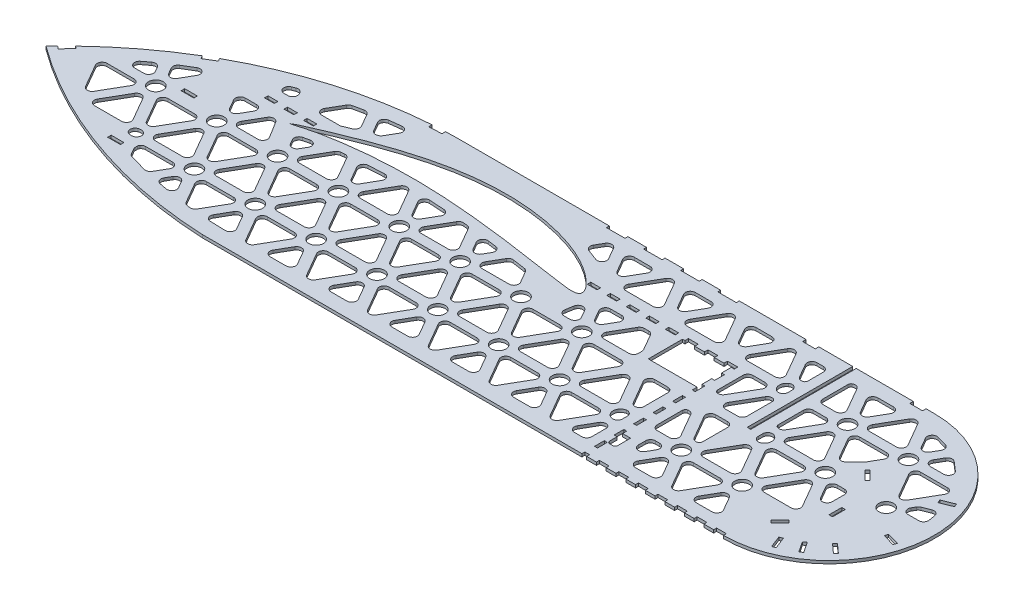
from build123d import *

# Parameters (mm, degrees)
BOSS_EXTRUDE1_DEPTH = 3
SKETCH2_R           = 7.5
SKETCH2_W           = 3.6
SKETCH2_H           = 13
SKETCH2_W_2         = 13
SKETCH2_H_2         = 3.6
SKETCH2_W_3         = 19
SKETCH2_H_3         = 3
SKETCH2_W_4         = 10
SKETCH2_W_5         = 3
SKETCH2_H_4         = 10
SKETCH2_W_6         = 4.93
SKETCH2_H_5         = 108
CUT_EXTRUDE1_DEPTH  = 934.342916617


with BuildPart() as part:
    # Sketch1 → Boss-Extrude1 (new body)
    with BuildSketch(Plane(origin=(0, 0, 0), x_dir=(1, 0, 0), z_dir=(0, 1, 0))):
        with BuildLine():
            Line((266.408252791, 0), (800, 0))
            ThreePointArc((800, 0), (908, 108), (800, 216))
            Line((800, 216), (316.294556964, 216))
            ThreePointArc((316.294556964, 216), (154.432198565, 182.326352039), (19.429068043, 86.893169221))
            ThreePointArc((19.429068043, 86.893169221), (136.475600537, 25.133273094), (266.408252791, 0))
        make_face()
    extrude(amount=BOSS_EXTRUDE1_DEPTH)

    # Sketch2 → Cut-Extrude1 (cut, through all)
    with BuildSketch(Plane.XZ):
        with Locations(Location((173.099021948, -108, 0), (0, 0, 90))):
            Circle(SKETCH2_R)
        with Locations(Location((204.259275985, -54.02885683, 0), (0, 0, 270))):
            Circle(SKETCH2_R)
        with Locations(Location((235.419021948, -108, 0), (0, 0, 90))):
            Circle(SKETCH2_R)
        with Locations(Location((266.579275985, -54.02885683, 0), (0, 0, 270))):
            Circle(SKETCH2_R)
        with Locations(Location((297.739021948, -108, 0), (0, 0, 90))):
            Circle(SKETCH2_R)
        with Locations(Location((328.899275985, -54.02885683, 0), (0, 0, 270))):
            Circle(SKETCH2_R)
        with Locations(Location((360.059021948, -108, 0), (0, 0, 90))):
            Circle(SKETCH2_R)
        with Locations(Location((391.219275985, -54.02885683, 0), (0, 0, 270))):
            Circle(SKETCH2_R)
        with Locations(Location((422.379021948, -108, 0), (0, 0, 90))):
            Circle(SKETCH2_R)
        with Locations(Location((453.539275985, -54.02885683, 0), (0, 0, 270))):
            Circle(SKETCH2_R)
        with Locations(Location((484.699021948, -108, 0), (0, 0, 90))):
            Circle(SKETCH2_R)
        with Locations(Location((515.859275985, -54.02885683, 0), (0, 0, 270))):
            Circle(SKETCH2_R)
        with Locations(Location((547.019021948, -108, 0), (0, 0, 90))):
            Circle(SKETCH2_R)
        with Locations(Location((578.179275985, -54.02885683, 0), (0, 0, 270))):
            Circle(SKETCH2_R)
        with Locations(Location((702.819275985, -54.02885683, 0), (0, 0, 270))):
            Circle(SKETCH2_R)
        with Locations(Location((765.139275985, -54.02885683, 0), (0, 0, 270))):
            Circle(SKETCH2_R)
        with Locations(Location((796.299021948, -108, 0), (0, 0, 90))):
            Circle(SKETCH2_R)
        with Locations(Location((858.619021948, -108, 0), (0, 0, 90))):
            Circle(SKETCH2_R)
        with Locations(Location((765.139275985, -161.96885683, 0), (0, 0, 270))):
            Circle(SKETCH2_R)
        with Locations(Location((827.459275985, -161.96885683, 0), (0, 0, 270))):
            Circle(SKETCH2_R)
        Polygon((647.57, -153), (637.57, -153), (637.57, -156.6), (627.57, -156.6), (627.57, -153), (617.57, -153), (617.57, -156.6), (607.57, -156.6), (607.57, -153), (605.07, -153), (605.07, -118), (655.07, -118), (655.07, -113), (658.07, -113), (658.07, -123), (655.07, -123), (655.07, -133), (658.07, -133), (658.07, -143), (655.07, -143), (655.07, -153), (658.07, -153), (658.07, -156.6), (647.57, -156.6), align=None)
        Polygon((823.689305433, -121.232773417), (814.496917278, -130.425161573), (817.04250169, -132.970745985), (826.234889846, -123.77835783), align=None)
        Polygon((833.216286063, -28.127768374), (837.957262065, -16.0230938), (834.605198337, -14.710208137), (829.864222335, -26.814882712), align=None)
        with Locations((837.65655194, -78.816857664)):
            Rectangle(SKETCH2_W, SKETCH2_H)
        with BuildLine():
            Line((658.07, -25.473381029), (658.07, -33))
            Line((658.07, -33), (655.07, -33))
            Line((655.07, -33), (655.07, -43))
            Line((655.07, -43), (658.07, -43))
            Line((658.07, -43), (658.07, -38.673381029))
            Line((658.07, -38.673381029), (666.27, -38.673381029))
            Line((666.27, -38.673381029), (666.27, -25.473381029))
            ThreePointArc((666.27, -25.473381029), (665.537766953, -23.705614076), (663.77, -22.973381029))
            Line((663.77, -22.973381029), (660.57, -22.973381029))
            ThreePointArc((660.57, -22.973381029), (658.802233047, -23.705614076), (658.07, -25.473381029))
        make_face()
        with BuildLine():
            Line((212.57, -142.861782597), (212.57, -142.894782597))
            add(Edge.make_bspline(
                [(212.57, -142.894782597), (212.815137814, -143.060102486), (213.721483955, -143.671338431), (215.664179604, -144.820627165), (218.723437449, -146.377902142), (222.783765044, -148.180430449), (227.75908382, -150.380753256), (233.673151887, -152.972942719), (243.334631626, -157.073964415), (254.071597155, -161.528560196), (265.811315632, -166.151386352), (275.559769605, -169.792616013), (285.820264156, -173.389650289), (300.213165162, -178.042893994), (315.047470761, -182.21442891), (330.216772764, -185.678244178), (341.716798025, -187.862793988), (353.238408154, -189.570546018), (364.74982071, -190.789827969), (376.222154657, -191.489317525), (387.611451467, -191.686885836), (398.853751386, -191.364655348), (413.421420996, -190.296341642), (427.580802498, -188.300042396), (441.195366572, -185.427458978), (450.821943115, -182.919735681), (459.948918056, -180.069695278), (468.511745548, -176.887644359), (476.453624938, -173.424739179), (483.715148146, -169.728859345), (490.24814377, -165.884833696), (496.019667562, -162.00694583), (500.998027396, -158.185747413), (505.147593549, -154.484087589), (508.447339472, -150.982728864), (510.852240131, -147.780842115), (512.23052565, -145.118995071), (512.672376723, -143.038033672), (512.365957104, -141.293980261), (510.836297954, -139.867947677), (508.300825673, -139.204557497), (504.990749494, -138.996901122), (500.845143819, -139.232879923), (495.886387834, -139.807005807), (490.127383335, -140.633765729), (483.600688534, -141.61415409), (476.345974836, -142.681971784), (468.41886468, -143.870863791), (459.86962452, -145.152957933), (447.40415706, -147.014008038), (434.302787697, -148.89198326), (413.230560269, -151.680307043), (394.916461571, -153.770522792), (372.413070638, -155.785169178), (353.278576878, -157.097400442), (334.10390548, -157.72050793), (318.83753012, -157.719300437), (307.569298967, -157.463067348), (296.54483902, -156.942386113), (285.853643217, -156.19861473), (275.586288909, -155.254588864), (265.829573747, -154.156930461), (256.673464041, -152.912824912), (248.205041684, -151.55854436), (240.510067524, -150.123302558), (233.666056009, -148.664077742), (227.735558734, -147.229571507), (222.771530443, -145.80558608), (218.774640723, -144.512633605), (215.724793866, -143.595242016), (213.753356987, -143.096728121), (212.816237246, -142.910670921), (212.57, -142.861782597)],
                knots=[0, 0, 0, 0, 0.001413477, 0.005226038, 0.010781091, 0.017815608, 0.026460951, 0.036790889, 0.048685593, 0.076639155, 0.092362872, 0.109003461, 0.126386903, 0.144339126, 0.181312719, 0.200023431, 0.218712626, 0.237261299, 0.255692478, 0.274037197, 0.292192583, 0.310132767, 0.327788163, 0.362001934, 0.378421226, 0.394286639, 0.40954344, 0.424114253, 0.43793778, 0.450941833, 0.463044023, 0.474154417, 0.484164575, 0.493023962, 0.500713088, 0.507125739, 0.512129705, 0.514904185, 0.517171427, 0.520261618, 0.5242453, 0.529497961, 0.536092185, 0.54406114, 0.553363127, 0.563904543, 0.575614949, 0.588420092, 0.60222661, 0.616944448, 0.648675826, 0.665501113, 0.718564132, 0.736789145, 0.773513212, 0.810244924, 0.828488569, 0.846493195, 0.864125178, 0.88124851, 0.897725282, 0.913415058, 0.928184346, 0.941897285, 0.954411455, 0.965602702, 0.975349728, 0.983575522, 0.990284579, 0.99543259, 0.998799869, 1, 1, 1, 1], degree=3))
        make_face()
        with Locations((134.542485822, -118.459135811)):
            Rectangle(SKETCH2_W_2, SKETCH2_H_2)
        with Locations((138.193962825, -39.604200299)):
            Rectangle(SKETCH2_W_2, SKETCH2_H_2)
        Polygon((879.46612068, -142.176464253), (891.512779688, -147.062976991), (892.865967831, -143.726979112), (880.819308823, -138.840466374), align=None)
        Polygon((883.56409693, -85.640734603), (896.049682188, -82.019939003), (895.047000329, -78.562392317), (882.561415072, -82.183187916), align=None)
        Polygon((865.40073975, -51.381643569), (875.050147879, -42.670218728), (872.637753308, -39.998074939), (862.988345179, -48.709499779), align=None)
        Polygon((849.114653162, -36.791532178), (856.271451565, -25.938871831), (853.266099469, -23.956989196), (846.109301065, -34.809649543), align=None)
        Polygon((822.408918344, -44.734564455), (813.216530188, -35.542176299), (810.670945776, -38.087760711), (819.863333931, -47.280148867), align=None)
        with Locations((785, -214.2)):
            Rectangle(SKETCH2_W_2, SKETCH2_H_2)
        with Locations((675.107627624, -214.2)):
            Rectangle(SKETCH2_W_2, SKETCH2_H_2)
        with Locations((590.701810534, -214.5)):
            Rectangle(SKETCH2_W_3, SKETCH2_H_3)
        with Locations((552.701810534, -214.5)):
            Rectangle(SKETCH2_W_3, SKETCH2_H_3)
        with Locations((514.701810534, -214.5)):
            Rectangle(SKETCH2_W_3, SKETCH2_H_3)
        with Locations((476.701810534, -214.5)):
            Rectangle(SKETCH2_W_3, SKETCH2_H_3)
        Polygon((286.653605669, -215.067910052), (299.639993398, -215.662665262), (299.804694841, -212.066434814), (286.818307112, -211.471679604), align=None)
        Polygon((107.891846949, -158.40758228), (119.051202256, -165.076074548), (120.897861653, -161.98579154), (109.738506346, -155.317299272), align=None)
        Polygon((25.225136805, -93.110530953), (34.089712558, -102.619437132), (36.722948115, -100.164631538), (27.858372362, -90.65572536), align=None)
        with Locations((532.57, -154.8)):
            Rectangle(SKETCH2_W_4, SKETCH2_H_2)
        with Locations((552.57, -154.8)):
            Rectangle(SKETCH2_W_4, SKETCH2_H_2)
        with Locations((572.57, -154.8)):
            Rectangle(SKETCH2_W_4, SKETCH2_H_2)
        with Locations((592.57, -154.8)):
            Rectangle(SKETCH2_W_4, SKETCH2_H_2)
        with Locations((656.57, -98)):
            Rectangle(SKETCH2_W_5, SKETCH2_H_4)
        with Locations((656.57, -78)):
            Rectangle(SKETCH2_W_5, SKETCH2_H_4)
        with Locations((656.57, -58)):
            Rectangle(SKETCH2_W_5, SKETCH2_H_4)
        with Locations((656.57, -18)):
            Rectangle(SKETCH2_W_5, SKETCH2_H_4)
        with Locations((657.535, -1.5)):
            Rectangle(SKETCH2_W_6, SKETCH2_H_3)
        with Locations((675, -1.5)):
            Rectangle(SKETCH2_W_4, SKETCH2_H_3)
        with Locations((695, -1.5)):
            Rectangle(SKETCH2_W_4, SKETCH2_H_3)
        with Locations((715, -1.5)):
            Rectangle(SKETCH2_W_4, SKETCH2_H_3)
        with Locations((735, -1.5)):
            Rectangle(SKETCH2_W_4, SKETCH2_H_3)
        with Locations((755, -1.5)):
            Rectangle(SKETCH2_W_4, SKETCH2_H_3)
        with Locations((775, -1.5)):
            Rectangle(SKETCH2_W_4, SKETCH2_H_3)
        with Locations((795, -1.5)):
            Rectangle(SKETCH2_W_4, SKETCH2_H_3)
        with Locations((182.07, -154.8)):
            Rectangle(SKETCH2_W_4, SKETCH2_H_2)
        with Locations((202.07, -154.8)):
            Rectangle(SKETCH2_W_4, SKETCH2_H_2)
        with Locations((222.07, -154.8)):
            Rectangle(SKETCH2_W_4, SKETCH2_H_2)
        with Locations((512.57, -154.8)):
            Rectangle(SKETCH2_W_4, SKETCH2_H_2)
        with BuildLine():
            Line((92.609657042, -66.52885683), (106.449403004, -90.5))
            ThreePointArc((106.449403004, -90.5), (110.779530023, -93), (115.109657042, -90.5))
            Line((115.109657042, -90.5), (128.949403004, -66.52885683))
            ThreePointArc((128.949403004, -66.52885683), (128.949403004, -61.52885683), (124.619275985, -59.02885683))
            Line((124.619275985, -59.02885683), (96.939784061, -59.02885683))
            ThreePointArc((96.939784061, -59.02885683), (92.609657042, -61.52885683), (92.609657042, -66.52885683))
        make_face()
        with Locations((718.2, -162)):
            Rectangle(SKETCH2_W, SKETCH2_H_5)
        with BuildLine():
            Line((645.07, -98), (645.07, -72.790783298))
            ThreePointArc((645.07, -72.790783298), (644.904453921, -71.807995952), (644.426086022, -70.933673))
            ThreePointArc((644.426086022, -70.933673), (640.139794282, -69.041796282), (636.169148966, -71.52885683))
            Line((636.169148966, -71.52885683), (622.329403004, -95.5))
            ThreePointArc((622.329403004, -95.5), (622.329403004, -100.5), (626.659530023, -103))
            Line((626.659530023, -103), (640.07, -103))
            ThreePointArc((640.07, -103), (643.605533906, -101.535533906), (645.07, -98))
        make_face()
        with BuildLine():
            Line((706.4, -98), (706.4, -72.115023081))
            ThreePointArc((706.4, -72.115023081), (705.809694801, -70.32802253), (704.271086022, -69.244272457))
            ThreePointArc((704.271086022, -69.244272457), (700.981884192, -69.378696467), (698.489148966, -71.52885683))
            Line((698.489148966, -71.52885683), (684.649403004, -95.5))
            ThreePointArc((684.649403004, -95.5), (684.649403004, -100.5), (688.979530023, -103))
            Line((688.979530023, -103), (701.4, -103))
            ThreePointArc((701.4, -103), (704.935533906, -101.535533906), (706.4, -98))
        make_face()
        with BuildLine():
            Line((552.794352734, -143), (541.244707312, -143))
            ThreePointArc((541.244707312, -143), (536.914580293, -140.5), (536.914580293, -135.5))
            Line((536.914580293, -135.5), (542.689403004, -125.497713659))
            ThreePointArc((542.689403004, -125.497713659), (547.019530023, -122.997713659), (551.349657042, -125.497713659))
            Line((551.349657042, -125.497713659), (557.124479753, -135.5))
            ThreePointArc((557.124479753, -135.5), (557.124479753, -140.5), (552.794352734, -143))
        make_face()
        with BuildLine():
            Line((575.887855426, -143), (580.470696544, -143))
            ThreePointArc((580.470696544, -143), (582.970696544, -142.330127019), (584.800823563, -140.5))
            Line((584.800823563, -140.5), (594.400127019, -123.873518698))
            ThreePointArc((594.400127019, -123.873518698), (594.899629131, -122.667613923), (595.07, -121.373518698))
            Line((595.07, -121.373518698), (595.07, -117.997713659))
            ThreePointArc((595.07, -117.997713659), (593.605533906, -114.462179753), (590.07, -112.997713659))
            Line((590.07, -112.997713659), (564.339530023, -112.997713659))
            ThreePointArc((564.339530023, -112.997713659), (560.009403004, -115.497713659), (560.009403004, -120.497713659))
            Line((560.009403004, -120.497713659), (571.557728407, -140.5))
            ThreePointArc((571.557728407, -140.5), (573.387855426, -142.330127019), (575.887855426, -143))
        make_face()
        with BuildLine():
            Line((520.098230566, -126.918739873), (518.751948683, -118.817465479))
            ThreePointArc((518.751948683, -118.817465479), (519.869968887, -114.765024062), (523.684305814, -112.997799001))
            Line((523.684305814, -112.997799001), (529.698508401, -112.997799001))
            ThreePointArc((529.698508401, -112.997799001), (534.039307761, -115.500026879), (534.030725675, -120.510377144))
            Line((534.030725675, -120.510377144), (529.360714716, -128.599073396))
            ThreePointArc((529.360714716, -128.599073396), (524.138090939, -131.018773543), (520.098230566, -126.918739873))
        make_face()
        with BuildLine():
            Line((645.07, -56.491725508), (645.07, -51.565988151))
            ThreePointArc((645.07, -51.565988151), (643.287704162, -47.738929238), (639.211448029, -46.640250794))
            ThreePointArc((639.211448029, -46.640250794), (632.999275985, -54.02885683), (639.211448029, -61.417462866))
            ThreePointArc((639.211448029, -61.417462866), (643.287704162, -60.318784422), (645.07, -56.491725508))
        make_face()
        with BuildLine():
            Line((632.399711718, -15), (640.07, -15))
            ThreePointArc((640.07, -15), (643.605533906, -16.464466094), (645.07, -20))
            Line((645.07, -20), (645.07, -35.266930361))
            ThreePointArc((645.07, -35.266930361), (644.904453921, -36.249717707), (644.426086022, -37.124040659))
            ThreePointArc((644.426086022, -37.124040659), (640.139794282, -39.015917377), (636.169148966, -36.52885683))
            Line((636.169148966, -36.52885683), (628.069584699, -22.5))
            ThreePointArc((628.069584699, -22.5), (628.069584699, -17.5), (632.399711718, -15))
        make_face()
        with BuildLine():
            Line((586.278840252, -15), (570.079711718, -15))
            ThreePointArc((570.079711718, -15), (565.749584699, -17.5), (565.749584699, -22.5))
            Line((565.749584699, -22.5), (573.849148966, -36.52885683))
            ThreePointArc((573.849148966, -36.52885683), (578.179275985, -39.02885683), (582.509403004, -36.52885683))
            Line((582.509403004, -36.52885683), (590.608967271, -22.5))
            ThreePointArc((590.608967271, -22.5), (590.608967271, -17.5), (586.278840252, -15))
        make_face()
        with BuildLine():
            Line((523.958840252, -15), (507.759711718, -15))
            ThreePointArc((507.759711718, -15), (503.429584699, -17.5), (503.429584699, -22.5))
            Line((503.429584699, -22.5), (511.529148966, -36.52885683))
            ThreePointArc((511.529148966, -36.52885683), (515.859275985, -39.02885683), (520.189403004, -36.52885683))
            Line((520.189403004, -36.52885683), (528.288967271, -22.5))
            ThreePointArc((528.288967271, -22.5), (528.288967271, -17.5), (523.958840252, -15))
        make_face()
        with BuildLine():
            Line((461.638840252, -15), (445.439711718, -15))
            ThreePointArc((445.439711718, -15), (441.109584699, -17.5), (441.109584699, -22.5))
            Line((441.109584699, -22.5), (449.209148966, -36.52885683))
            ThreePointArc((449.209148966, -36.52885683), (453.539275985, -39.02885683), (457.869403004, -36.52885683))
            Line((457.869403004, -36.52885683), (465.968967271, -22.5))
            ThreePointArc((465.968967271, -22.5), (465.968967271, -17.5), (461.638840252, -15))
        make_face()
        with BuildLine():
            Line((399.318840252, -15), (383.119711718, -15))
            ThreePointArc((383.119711718, -15), (378.789584699, -17.5), (378.789584699, -22.5))
            Line((378.789584699, -22.5), (386.889148966, -36.52885683))
            ThreePointArc((386.889148966, -36.52885683), (391.219275985, -39.02885683), (395.549403004, -36.52885683))
            Line((395.549403004, -36.52885683), (403.648967271, -22.5))
            ThreePointArc((403.648967271, -22.5), (403.648967271, -17.5), (399.318840252, -15))
        make_face()
        with BuildLine():
            Line((336.998840252, -15), (320.799711718, -15))
            ThreePointArc((320.799711718, -15), (316.469584699, -17.5), (316.469584699, -22.5))
            Line((316.469584699, -22.5), (324.569148966, -36.52885683))
            ThreePointArc((324.569148966, -36.52885683), (328.899275985, -39.02885683), (333.229403004, -36.52885683))
            Line((333.229403004, -36.52885683), (341.328967271, -22.5))
            ThreePointArc((341.328967271, -22.5), (341.328967271, -17.5), (336.998840252, -15))
        make_face()
        with BuildLine():
            Line((274.360045884, -15.282400069), (258.767288601, -15.772807908))
            ThreePointArc((258.767288601, -15.772807908), (254.555574733, -18.338713906), (254.594338874, -23.270336827))
            Line((254.594338874, -23.270336827), (262.249148966, -36.52885683))
            ThreePointArc((262.249148966, -36.52885683), (266.579275985, -39.02885683), (270.909403004, -36.52885683))
            Line((270.909403004, -36.52885683), (278.847350195, -22.779928988))
            ThreePointArc((278.847350195, -22.779928988), (278.807515978, -17.712169718), (274.360045884, -15.282400069))
        make_face()
        with BuildLine():
            Line((236.201288355, -17.460544209), (233.266650301, -17.806658494))
            ThreePointArc((233.266650301, -17.806658494), (231.102572468, -18.596236849), (229.522169389, -20.272241908))
            Line((229.522169389, -20.272241908), (217.249657042, -41.52885683))
            ThreePointArc((217.249657042, -41.52885683), (217.249657042, -46.52885683), (221.579784061, -49.02885683))
            Line((221.579784061, -49.02885683), (249.259275985, -49.02885683))
            ThreePointArc((249.259275985, -49.02885683), (253.589403004, -46.52885683), (253.589403004, -41.52885683))
            Line((253.589403004, -41.52885683), (241.117061481, -19.926127623))
            ThreePointArc((241.117061481, -19.926127623), (239.028598959, -17.956794307), (236.201288355, -17.460544209))
        make_face()
        with BuildLine():
            Line((207.494633676, -21.910678436), (199.990539022, -23.321819719))
            ThreePointArc((199.990539022, -23.321819719), (196.371136733, -26.148340424), (196.58446304, -30.735690869))
            Line((196.58446304, -30.735690869), (199.929148966, -36.52885683))
            ThreePointArc((199.929148966, -36.52885683), (204.259275985, -39.02885683), (208.589403004, -36.52885683))
            Line((208.589403004, -36.52885683), (212.748811731, -29.324549586))
            ThreePointArc((212.748811731, -29.324549586), (212.498109887, -23.933478808), (207.494633676, -21.910678436))
        make_face()
        with BuildLine():
            Line((179.150055874, -27.997329576), (161.65211917, -32.779123773))
            ThreePointArc((161.65211917, -32.779123773), (159.91653169, -33.643069948), (158.640049569, -35.102268457))
            Line((158.640049569, -35.102268457), (155.095886614, -41.240938766))
            ThreePointArc((155.095886614, -41.240938766), (154.796185346, -41.964481631), (154.693962825, -42.740938766))
            Line((154.693962825, -42.740938766), (154.693962825, -45.273125232))
            ThreePointArc((154.693962825, -45.273125232), (154.861455494, -46.261508871), (155.345230971, -47.139527835))
            ThreePointArc((155.345230971, -47.139527835), (157.086463448, -48.531820022), (159.259784061, -49.02885683))
            Line((159.259784061, -49.02885683), (186.939275985, -49.02885683))
            ThreePointArc((186.939275985, -49.02885683), (191.269403004, -46.52885683), (191.269403004, -41.52885683))
            Line((191.269403004, -41.52885683), (184.79824031, -30.32047426))
            ThreePointArc((184.79824031, -30.32047426), (182.37005733, -28.19634095), (179.150055874, -27.997329576))
        make_face()
        with BuildLine():
            Line((142.718854976, -51.404200299), (141.159696995, -51.404200299))
            ThreePointArc((141.159696995, -51.404200299), (136.222418661, -55.614717777), (139.600539014, -61.154887238))
            ThreePointArc((139.600539014, -61.154887238), (141.939275985, -61.52885683), (144.278012956, -61.154887238))
            ThreePointArc((144.278012956, -61.154887238), (147.65613331, -55.614717777), (142.718854976, -51.404200299))
        make_face()
        with BuildLine():
            Line((461.250493905, -134.830482432), (448.398783221, -136.738958248))
            ThreePointArc((448.398783221, -136.738958248), (445.490016846, -136.29567329), (443.33421135, -134.293193316))
            Line((443.33421135, -134.293193316), (435.369408259, -120.497749691))
            ThreePointArc((435.369408259, -120.497749691), (435.369408259, -115.497749691), (439.699535278, -112.997749691))
            Line((439.699535278, -112.997749691), (467.379027202, -112.997749691))
            ThreePointArc((467.379027202, -112.997749691), (471.709128657, -115.49776445), (471.709120136, -120.497749691))
            Line((471.709120136, -120.497749691), (464.846176071, -132.3847175))
            ThreePointArc((464.846176071, -132.3847175), (463.328150328, -134.018975162), (461.250493905, -134.830482432))
        make_face()
        with BuildLine():
            Line((426.925845652, -139.720641866), (418.485277787, -140.811782521))
            ThreePointArc((418.485277787, -140.811782521), (413.683650741, -138.626031677), (413.514118066, -133.353045074))
            Line((413.514118066, -133.353045074), (418.049401778, -125.497703258))
            ThreePointArc((418.049401778, -125.497703258), (422.379528796, -122.997728552), (426.709641212, -125.497728552))
            Line((426.709641212, -125.497728552), (430.614939969, -132.261904418))
            ThreePointArc((430.614939969, -132.261904418), (430.766586965, -136.978591513), (426.925845652, -139.720641866))
        make_face()
        with BuildLine():
            Line((390.081136777, -144.101768792), (393.565851943, -143.749730032))
            ThreePointArc((393.565851943, -143.749730032), (395.778015499, -142.9738928), (397.39341855, -141.275050843))
            Line((397.39341855, -141.275050843), (409.389214293, -120.49772314))
            ThreePointArc((409.389214293, -120.49772314), (409.389198193, -115.497695254), (405.059022874, -112.997723141))
            Line((405.059022874, -112.997723141), (377.37953095, -112.997723141))
            ThreePointArc((377.37953095, -112.997723141), (373.049403931, -115.497723141), (373.049403931, -120.497723141))
            Line((373.049403931, -120.497723141), (385.248449346, -141.627089603))
            ThreePointArc((385.248449346, -141.627089603), (387.299634548, -143.577530502), (390.081136777, -144.101768792))
        make_face()
        with BuildLine():
            Line((367.81241942, -145.896789835), (352.370989088, -146.825868409))
            ThreePointArc((352.370989088, -146.825868409), (347.817628234, -144.463856765), (347.740565597, -139.334894353))
            Line((347.740565597, -139.334894353), (355.729482648, -125.497684124))
            ThreePointArc((355.729482648, -125.497684124), (360.059513786, -122.997684126), (364.389640802, -125.497518057))
            Line((364.389640802, -125.497518057), (371.842249966, -138.405815779))
            ThreePointArc((371.842249966, -138.405815779), (371.915403372, -143.274596371), (367.81241942, -145.896789835))
        make_face()
        with BuildLine():
            Line((305.606957716, -147.098174328), (289.823230268, -146.21830924))
            ThreePointArc((289.823230268, -146.21830924), (285.703474664, -143.604539669), (285.771396564, -138.726059965))
            Line((285.771396564, -138.726059965), (293.409519005, -125.496443823))
            ThreePointArc((293.409519005, -125.496443823), (297.739795297, -122.996883553), (302.069668432, -125.497142128))
            Line((302.069668432, -125.497142128), (310.215378051, -139.605925052))
            ThreePointArc((310.215378051, -139.605925052), (310.144099338, -144.725507291), (305.606957716, -147.098174328))
        make_face()
        with BuildLine():
            Line((267.512893821, -144.227720176), (264.147831755, -143.802865237))
            ThreePointArc((264.147831755, -143.802865237), (262.007328638, -143.006953567), (260.444006324, -141.342245687))
            Line((260.444006324, -141.342245687), (248.409404394, -120.497703695))
            ThreePointArc((248.409404394, -120.497703695), (248.409404394, -115.497703695), (252.739531412, -112.997703695))
            Line((252.739531412, -112.997703695), (280.419023337, -112.997703695))
            ThreePointArc((280.419023337, -112.997703695), (284.749214472, -115.497703695), (284.749182413, -120.497759221))
            Line((284.749182413, -120.497759221), (272.469322428, -141.767100626))
            ThreePointArc((272.469322428, -141.767100626), (270.36253588, -143.745577727), (267.512893821, -144.227720176))
        make_face()
        with BuildLine():
            Line((237.806112566, -138.941760555), (231.616362159, -137.521362349))
            ThreePointArc((231.616362159, -137.521362349), (228.150693228, -134.644805491), (228.404547422, -130.14802903))
            Line((228.404547422, -130.14802903), (231.08939692, -125.497733288))
            ThreePointArc((231.08939692, -125.497733288), (235.419530179, -122.997747037), (239.74964926, -125.497757845))
            Line((239.74964926, -125.497757845), (243.254551867, -131.568427236))
            ThreePointArc((243.254551867, -131.568427236), (242.945674596, -137.039883186), (237.806112566, -138.941760555))
        make_face()
        with BuildLine():
            Line((204.249137645, -137.30425651), (214.592258392, -120.578024173))
            ThreePointArc((214.592258392, -120.578024173), (214.707068234, -115.514032178), (210.33965721, -112.948312555))
            Line((210.33965721, -112.948312555), (190.339641721, -112.948312555))
            ThreePointArc((190.339641721, -112.948312555), (186.009514703, -115.448312555), (186.009514703, -120.448312555))
            Line((186.009514703, -120.448312555), (195.666409445, -137.174544892))
            ThreePointArc((195.666409445, -137.174544892), (199.920979599, -139.673973975), (204.249137645, -137.30425651))
        make_face()
        with BuildLine():
            Line((238.789055642, -193.178883666), (228.708647314, -191.019501181))
            ThreePointArc((228.708647314, -191.019501181), (226.813830813, -190.173170795), (225.425838811, -188.630419066))
            Line((225.425838811, -188.630419066), (217.249657042, -174.46885683))
            ThreePointArc((217.249657042, -174.46885683), (217.249657042, -169.46885683), (221.579784061, -166.96885683))
            Line((221.579784061, -166.96885683), (239.84086708, -166.96885683))
            ThreePointArc((239.84086708, -166.96885683), (240.783887599, -167.058590818), (241.693059721, -167.324571909))
            Line((241.693059721, -167.324571909), (249.348723497, -170.377736034))
            ThreePointArc((249.348723497, -170.377736034), (252.220456221, -173.383567674), (251.826657875, -177.522020954))
            Line((251.826657875, -177.522020954), (244.166501176, -190.789801551))
            ThreePointArc((244.166501176, -190.789801551), (241.866432347, -192.859141081), (238.789055642, -193.178883666))
        make_face()
        with BuildLine():
            Line((269.328402826, -178.125373168), (268.074244735, -177.665632673))
            ThreePointArc((268.074244735, -177.665632673), (264.648654227, -177.659732833), (262.023232079, -179.860156357))
            Line((262.023232079, -179.860156357), (256.580365767, -189.287477348))
            ThreePointArc((256.580365767, -189.287477348), (256.43282805, -194.012453418), (260.287815062, -196.748553083))
            Line((260.287815062, -196.748553083), (272.511141878, -198.28273513))
            ThreePointArc((272.511141878, -198.28273513), (277.29953777, -196.086942771), (277.463946621, -190.821659395))
            Line((277.463946621, -190.821659395), (270.893947655, -179.442087379))
            ThreePointArc((270.893947655, -179.442087379), (270.22687169, -178.646169687), (269.328402826, -178.125373168))
        make_face()
        with BuildLine():
            Line((184.368562123, -177.893150023), (181.14199607, -176.619756451))
            ThreePointArc((181.14199607, -176.619756451), (178.065566192, -171.034645425), (182.97751581, -166.96885683))
            Line((182.97751581, -166.96885683), (186.939275985, -166.96885683))
            ThreePointArc((186.939275985, -166.96885683), (191.269403004, -169.46885683), (191.269403004, -174.46885683))
            Line((191.269403004, -174.46885683), (190.534208882, -175.742250402))
            ThreePointArc((190.534208882, -175.742250402), (187.851005864, -177.963229256), (184.368562123, -177.893150023))
        make_face()
        with BuildLine():
            Line((118.042485822, -109.061475996), (118.042485822, -106.938524004))
            ThreePointArc((118.042485822, -106.938524004), (117.922784929, -105.851012796), (117.56941357, -104.815572013))
            ThreePointArc((117.56941357, -104.815572013), (103.279021948, -108), (117.56941357, -111.184427987))
            ThreePointArc((117.56941357, -111.184427987), (117.922784929, -110.148987204), (118.042485822, -109.061475996))
        make_face()
        with BuildLine():
            Line((115.614267358, -145.121874875), (104.611437032, -138.498480715))
            ThreePointArc((104.611437032, -138.498480715), (102.348875447, -135.464671899), (102.859997042, -131.714747156))
            Line((102.859997042, -131.714747156), (106.449403004, -125.497713659))
            ThreePointArc((106.449403004, -125.497713659), (110.779530023, -122.997713659), (115.109657042, -125.497713659))
            Line((115.109657042, -125.497713659), (122.523081406, -138.338141315))
            ThreePointArc((122.523081406, -138.338141315), (121.696045274, -144.405823229), (115.614267358, -145.121874875))
        make_face()
        with BuildLine():
            Line((87.602210949, -126.905375895), (81.09773809, -121.985445702))
            ThreePointArc((81.09773809, -121.985445702), (79.37384357, -116.406905722), (84.114026067, -112.997713659))
            Line((84.114026067, -112.997713659), (93.459021948, -112.997713659))
            ThreePointArc((93.459021948, -112.997713659), (97.789148966, -115.497713659), (97.789148966, -120.497713659))
            Line((97.789148966, -120.497713659), (94.948625945, -125.417643853))
            ThreePointArc((94.948625945, -125.417643853), (91.610910088, -127.818166283), (87.602210949, -126.905375895))
        make_face()
        with BuildLine():
            Line((178.874352734, -143), (167.324707312, -143))
            ThreePointArc((167.324707312, -143), (162.994580293, -140.5), (162.994580293, -135.5))
            Line((162.994580293, -135.5), (168.769403004, -125.497713659))
            ThreePointArc((168.769403004, -125.497713659), (173.099530023, -122.997713659), (177.429657042, -125.497713659))
            Line((177.429657042, -125.497713659), (183.204479753, -135.5))
            ThreePointArc((183.204479753, -135.5), (183.204479753, -140.5), (178.874352734, -143))
        make_face()
        with BuildLine():
            Line((61.449403004, -95.5), (75.289148966, -71.52885683))
            ThreePointArc((75.289148966, -71.52885683), (79.619275985, -69.02885683), (83.949403004, -71.52885683))
            Line((83.949403004, -71.52885683), (97.789148966, -95.5))
            ThreePointArc((97.789148966, -95.5), (97.789148966, -100.5), (93.459021948, -103))
            Line((93.459021948, -103), (65.779530023, -103))
            ThreePointArc((65.779530023, -103), (61.449403004, -100.5), (61.449403004, -95.5))
        make_face()
        with BuildLine():
            Line((123.769403004, -95.5), (137.609148966, -71.52885683))
            ThreePointArc((137.609148966, -71.52885683), (141.939275985, -69.02885683), (146.269403004, -71.52885683))
            Line((146.269403004, -71.52885683), (160.109148966, -95.5))
            ThreePointArc((160.109148966, -95.5), (160.109148966, -100.5), (155.779021948, -103))
            Line((155.779021948, -103), (128.099530023, -103))
            ThreePointArc((128.099530023, -103), (123.769403004, -100.5), (123.769403004, -95.5))
        make_face()
        with BuildLine():
            Line((154.929657042, -66.52885683), (168.769403004, -90.5))
            ThreePointArc((168.769403004, -90.5), (173.099530023, -93), (177.429657042, -90.5))
            Line((177.429657042, -90.5), (191.269403004, -66.52885683))
            ThreePointArc((191.269403004, -66.52885683), (191.269403004, -61.52885683), (186.939275985, -59.02885683))
            Line((186.939275985, -59.02885683), (159.259784061, -59.02885683))
            ThreePointArc((159.259784061, -59.02885683), (154.929657042, -61.52885683), (154.929657042, -66.52885683))
        make_face()
        with BuildLine():
            Line((186.089403004, -95.5), (199.929148966, -71.52885683))
            ThreePointArc((199.929148966, -71.52885683), (204.259275985, -69.02885683), (208.589403004, -71.52885683))
            Line((208.589403004, -71.52885683), (222.429148966, -95.5))
            ThreePointArc((222.429148966, -95.5), (222.429148966, -100.5), (218.099021948, -103))
            Line((218.099021948, -103), (190.419530023, -103))
            ThreePointArc((190.419530023, -103), (186.089403004, -100.5), (186.089403004, -95.5))
        make_face()
        with BuildLine():
            Line((217.249657042, -66.52885683), (231.089403004, -90.5))
            ThreePointArc((231.089403004, -90.5), (235.419530023, -93), (239.749657042, -90.5))
            Line((239.749657042, -90.5), (253.589403004, -66.52885683))
            ThreePointArc((253.589403004, -66.52885683), (253.589403004, -61.52885683), (249.259275985, -59.02885683))
            Line((249.259275985, -59.02885683), (221.579784061, -59.02885683))
            ThreePointArc((221.579784061, -59.02885683), (217.249657042, -61.52885683), (217.249657042, -66.52885683))
        make_face()
        with BuildLine():
            Line((248.409403004, -95.5), (262.249148966, -71.52885683))
            ThreePointArc((262.249148966, -71.52885683), (266.579275985, -69.02885683), (270.909403004, -71.52885683))
            Line((270.909403004, -71.52885683), (284.749148966, -95.5))
            ThreePointArc((284.749148966, -95.5), (284.749148966, -100.5), (280.419021948, -103))
            Line((280.419021948, -103), (252.739530023, -103))
            ThreePointArc((252.739530023, -103), (248.409403004, -100.5), (248.409403004, -95.5))
        make_face()
        with BuildLine():
            Line((279.569657042, -66.52885683), (293.409403004, -90.5))
            ThreePointArc((293.409403004, -90.5), (297.739530023, -93), (302.069657042, -90.5))
            Line((302.069657042, -90.5), (315.909403004, -66.52885683))
            ThreePointArc((315.909403004, -66.52885683), (315.909403004, -61.52885683), (311.579275985, -59.02885683))
            Line((311.579275985, -59.02885683), (283.899784061, -59.02885683))
            ThreePointArc((283.899784061, -59.02885683), (279.569657042, -61.52885683), (279.569657042, -66.52885683))
        make_face()
        with BuildLine():
            Line((311.579275985, -49.02885683), (283.899784061, -49.02885683))
            ThreePointArc((283.899784061, -49.02885683), (279.569657042, -46.52885683), (279.569657042, -41.52885683))
            Line((279.569657042, -41.52885683), (293.409403004, -17.557713659))
            ThreePointArc((293.409403004, -17.557713659), (297.739530023, -15.057713659), (302.069657042, -17.557713659))
            Line((302.069657042, -17.557713659), (315.909403004, -41.52885683))
            ThreePointArc((315.909403004, -41.52885683), (315.909403004, -46.52885683), (311.579275985, -49.02885683))
        make_face()
        with BuildLine():
            Line((310.729403004, -95.5), (324.569148966, -71.52885683))
            ThreePointArc((324.569148966, -71.52885683), (328.899275985, -69.02885683), (333.229403004, -71.52885683))
            Line((333.229403004, -71.52885683), (347.069148966, -95.5))
            ThreePointArc((347.069148966, -95.5), (347.069148966, -100.5), (342.739021948, -103))
            Line((342.739021948, -103), (315.059530023, -103))
            ThreePointArc((315.059530023, -103), (310.729403004, -100.5), (310.729403004, -95.5))
        make_face()
        with BuildLine():
            Line((341.889657042, -66.52885683), (355.729403004, -90.5))
            ThreePointArc((355.729403004, -90.5), (360.059530023, -93), (364.389657042, -90.5))
            Line((364.389657042, -90.5), (378.229403004, -66.52885683))
            ThreePointArc((378.229403004, -66.52885683), (378.229403004, -61.52885683), (373.899275985, -59.02885683))
            Line((373.899275985, -59.02885683), (346.219784061, -59.02885683))
            ThreePointArc((346.219784061, -59.02885683), (341.889657042, -61.52885683), (341.889657042, -66.52885683))
        make_face()
        with BuildLine():
            Line((373.899275985, -49.02885683), (346.219784061, -49.02885683))
            ThreePointArc((346.219784061, -49.02885683), (341.889657042, -46.52885683), (341.889657042, -41.52885683))
            Line((341.889657042, -41.52885683), (355.729403004, -17.557713659))
            ThreePointArc((355.729403004, -17.557713659), (360.059530023, -15.057713659), (364.389657042, -17.557713659))
            Line((364.389657042, -17.557713659), (378.229403004, -41.52885683))
            ThreePointArc((378.229403004, -41.52885683), (378.229403004, -46.52885683), (373.899275985, -49.02885683))
        make_face()
        with BuildLine():
            Line((373.049403004, -95.5), (386.889148966, -71.52885683))
            ThreePointArc((386.889148966, -71.52885683), (391.219275985, -69.02885683), (395.549403004, -71.52885683))
            Line((395.549403004, -71.52885683), (409.389148966, -95.5))
            ThreePointArc((409.389148966, -95.5), (409.389148966, -100.5), (405.059021948, -103))
            Line((405.059021948, -103), (377.379530023, -103))
            ThreePointArc((377.379530023, -103), (373.049403004, -100.5), (373.049403004, -95.5))
        make_face()
        with BuildLine():
            Line((404.209657042, -66.52885683), (418.049403004, -90.5))
            ThreePointArc((418.049403004, -90.5), (422.379530023, -93), (426.709657042, -90.5))
            Line((426.709657042, -90.5), (440.549403004, -66.52885683))
            ThreePointArc((440.549403004, -66.52885683), (440.549403004, -61.52885683), (436.219275985, -59.02885683))
            Line((436.219275985, -59.02885683), (408.539784061, -59.02885683))
            ThreePointArc((408.539784061, -59.02885683), (404.209657042, -61.52885683), (404.209657042, -66.52885683))
        make_face()
        with BuildLine():
            Line((436.219275985, -49.02885683), (408.539784061, -49.02885683))
            ThreePointArc((408.539784061, -49.02885683), (404.209657042, -46.52885683), (404.209657042, -41.52885683))
            Line((404.209657042, -41.52885683), (418.049403004, -17.557713659))
            ThreePointArc((418.049403004, -17.557713659), (422.379530023, -15.057713659), (426.709657042, -17.557713659))
            Line((426.709657042, -17.557713659), (440.549403004, -41.52885683))
            ThreePointArc((440.549403004, -41.52885683), (440.549403004, -46.52885683), (436.219275985, -49.02885683))
        make_face()
        with BuildLine():
            Line((435.369403004, -95.5), (449.209148966, -71.52885683))
            ThreePointArc((449.209148966, -71.52885683), (453.539275985, -69.02885683), (457.869403004, -71.52885683))
            Line((457.869403004, -71.52885683), (471.709148966, -95.5))
            ThreePointArc((471.709148966, -95.5), (471.709148966, -100.5), (467.379021948, -103))
            Line((467.379021948, -103), (439.699530023, -103))
            ThreePointArc((439.699530023, -103), (435.369403004, -100.5), (435.369403004, -95.5))
        make_face()
        with BuildLine():
            Line((466.529657042, -66.52885683), (480.369403004, -90.5))
            ThreePointArc((480.369403004, -90.5), (484.699530023, -93), (489.029657042, -90.5))
            Line((489.029657042, -90.5), (502.869403004, -66.52885683))
            ThreePointArc((502.869403004, -66.52885683), (502.869403004, -61.52885683), (498.539275985, -59.02885683))
            Line((498.539275985, -59.02885683), (470.859784061, -59.02885683))
            ThreePointArc((470.859784061, -59.02885683), (466.529657042, -61.52885683), (466.529657042, -66.52885683))
        make_face()
        with BuildLine():
            Line((498.539275985, -49.02885683), (470.859784061, -49.02885683))
            ThreePointArc((470.859784061, -49.02885683), (466.529657042, -46.52885683), (466.529657042, -41.52885683))
            Line((466.529657042, -41.52885683), (480.369403004, -17.557713659))
            ThreePointArc((480.369403004, -17.557713659), (484.699530023, -15.057713659), (489.029657042, -17.557713659))
            Line((489.029657042, -17.557713659), (502.869403004, -41.52885683))
            ThreePointArc((502.869403004, -41.52885683), (502.869403004, -46.52885683), (498.539275985, -49.02885683))
        make_face()
        with BuildLine():
            Line((497.689403004, -95.5), (511.529148966, -71.52885683))
            ThreePointArc((511.529148966, -71.52885683), (515.859275985, -69.02885683), (520.189403004, -71.52885683))
            Line((520.189403004, -71.52885683), (534.029148966, -95.5))
            ThreePointArc((534.029148966, -95.5), (534.029148966, -100.5), (529.699021948, -103))
            Line((529.699021948, -103), (502.019530023, -103))
            ThreePointArc((502.019530023, -103), (497.689403004, -100.5), (497.689403004, -95.5))
        make_face()
        with BuildLine():
            Line((528.849657042, -66.52885683), (542.689403004, -90.5))
            ThreePointArc((542.689403004, -90.5), (547.019530023, -93), (551.349657042, -90.5))
            Line((551.349657042, -90.5), (565.189403004, -66.52885683))
            ThreePointArc((565.189403004, -66.52885683), (565.189403004, -61.52885683), (560.859275985, -59.02885683))
            Line((560.859275985, -59.02885683), (533.179784061, -59.02885683))
            ThreePointArc((533.179784061, -59.02885683), (528.849657042, -61.52885683), (528.849657042, -66.52885683))
        make_face()
        with BuildLine():
            Line((560.859275985, -49.02885683), (533.179784061, -49.02885683))
            ThreePointArc((533.179784061, -49.02885683), (528.849657042, -46.52885683), (528.849657042, -41.52885683))
            Line((528.849657042, -41.52885683), (542.689403004, -17.557713659))
            ThreePointArc((542.689403004, -17.557713659), (547.019530023, -15.057713659), (551.349657042, -17.557713659))
            Line((551.349657042, -17.557713659), (565.189403004, -41.52885683))
            ThreePointArc((565.189403004, -41.52885683), (565.189403004, -46.52885683), (560.859275985, -49.02885683))
        make_face()
        with BuildLine():
            Line((560.009403004, -95.5), (573.849148966, -71.52885683))
            ThreePointArc((573.849148966, -71.52885683), (578.179275985, -69.02885683), (582.509403004, -71.52885683))
            Line((582.509403004, -71.52885683), (596.349148966, -95.5))
            ThreePointArc((596.349148966, -95.5), (596.349148966, -100.5), (592.019021948, -103))
            Line((592.019021948, -103), (564.339530023, -103))
            ThreePointArc((564.339530023, -103), (560.009403004, -100.5), (560.009403004, -95.5))
        make_face()
        with BuildLine():
            Line((591.169657042, -66.52885683), (605.009403004, -90.5))
            ThreePointArc((605.009403004, -90.5), (609.339530023, -93), (613.669657042, -90.5))
            Line((613.669657042, -90.5), (627.509403004, -66.52885683))
            ThreePointArc((627.509403004, -66.52885683), (627.509403004, -61.52885683), (623.179275985, -59.02885683))
            Line((623.179275985, -59.02885683), (595.499784061, -59.02885683))
            ThreePointArc((595.499784061, -59.02885683), (591.169657042, -61.52885683), (591.169657042, -66.52885683))
        make_face()
        with BuildLine():
            Line((623.179275985, -49.02885683), (595.499784061, -49.02885683))
            ThreePointArc((595.499784061, -49.02885683), (591.169657042, -46.52885683), (591.169657042, -41.52885683))
            Line((591.169657042, -41.52885683), (605.009403004, -17.557713659))
            ThreePointArc((605.009403004, -17.557713659), (609.339530023, -15.057713659), (613.669657042, -17.557713659))
            Line((613.669657042, -17.557713659), (627.509403004, -41.52885683))
            ThreePointArc((627.509403004, -41.52885683), (627.509403004, -46.52885683), (623.179275985, -49.02885683))
        make_face()
        with BuildLine():
            Line((675.989657042, -90.5), (689.829403004, -66.52885683))
            ThreePointArc((689.829403004, -66.52885683), (689.829403004, -61.52885683), (685.499275985, -59.02885683))
            Line((685.499275985, -59.02885683), (673.07, -59.02885683))
            ThreePointArc((673.07, -59.02885683), (669.534466094, -60.493322924), (668.07, -64.02885683))
            Line((668.07, -64.02885683), (668.07, -89.911139543))
            ThreePointArc((668.07, -89.911139543), (668.656197491, -91.692587675), (670.185704965, -92.777848857))
            ThreePointArc((670.185704965, -92.777848857), (673.486211188, -92.654378146), (675.989657042, -90.5))
        make_face()
        with BuildLine():
            Line((685.499275985, -49.02885683), (681.27, -49.02885683))
            ThreePointArc((681.27, -49.02885683), (677.734466094, -47.564390736), (676.27, -44.02885683))
            Line((676.27, -44.02885683), (676.27, -36.703535944))
            ThreePointArc((676.27, -36.703535944), (679.975904774, -31.873906812), (685.600127019, -34.203535944))
            Line((685.600127019, -34.203535944), (689.829403004, -41.52885683))
            ThreePointArc((689.829403004, -41.52885683), (689.829403004, -46.52885683), (685.499275985, -49.02885683))
        make_face()
        with BuildLine():
            Line((715.809657042, -66.52885683), (729.649403004, -90.5))
            ThreePointArc((729.649403004, -90.5), (733.979530023, -93), (738.309657042, -90.5))
            Line((738.309657042, -90.5), (752.149403004, -66.52885683))
            ThreePointArc((752.149403004, -66.52885683), (752.149403004, -61.52885683), (747.819275985, -59.02885683))
            Line((747.819275985, -59.02885683), (720.139784061, -59.02885683))
            ThreePointArc((720.139784061, -59.02885683), (715.809657042, -61.52885683), (715.809657042, -66.52885683))
        make_face()
        with BuildLine():
            Line((747.819275985, -49.02885683), (720.139784061, -49.02885683))
            ThreePointArc((720.139784061, -49.02885683), (715.809657042, -46.52885683), (715.809657042, -41.52885683))
            Line((715.809657042, -41.52885683), (729.649403004, -17.557713659))
            ThreePointArc((729.649403004, -17.557713659), (733.979530023, -15.057713659), (738.309657042, -17.557713659))
            Line((738.309657042, -17.557713659), (752.149403004, -41.52885683))
            ThreePointArc((752.149403004, -41.52885683), (752.149403004, -46.52885683), (747.819275985, -49.02885683))
        make_face()
        with BuildLine():
            Line((707.149403004, -36.52885683), (715.248967271, -22.5))
            ThreePointArc((715.248967271, -22.5), (715.248967271, -17.5), (710.918840252, -15))
            Line((710.918840252, -15), (694.719711718, -15))
            ThreePointArc((694.719711718, -15), (690.389584699, -17.5), (690.389584699, -22.5))
            Line((690.389584699, -22.5), (698.489148966, -36.52885683))
            ThreePointArc((698.489148966, -36.52885683), (702.819275985, -39.02885683), (707.149403004, -36.52885683))
        make_face()
        with BuildLine():
            Line((746.969403004, -95.5), (760.809148966, -71.52885683))
            ThreePointArc((760.809148966, -71.52885683), (765.139275985, -69.02885683), (769.469403004, -71.52885683))
            Line((769.469403004, -71.52885683), (783.309148966, -95.5))
            ThreePointArc((783.309148966, -95.5), (783.309148966, -100.5), (778.979021948, -103))
            Line((778.979021948, -103), (751.299530023, -103))
            ThreePointArc((751.299530023, -103), (746.969403004, -100.5), (746.969403004, -95.5))
        make_face()
        with BuildLine():
            Line((778.129657042, -66.52885683), (791.969403004, -90.5))
            ThreePointArc((791.969403004, -90.5), (796.299530023, -93), (800.629657042, -90.5))
            Line((800.629657042, -90.5), (814.469403004, -66.52885683))
            ThreePointArc((814.469403004, -66.52885683), (814.469403004, -61.52885683), (810.139275985, -59.02885683))
            Line((810.139275985, -59.02885683), (782.459784061, -59.02885683))
            ThreePointArc((782.459784061, -59.02885683), (778.129657042, -61.52885683), (778.129657042, -66.52885683))
        make_face()
        with BuildLine():
            Line((769.469403004, -36.52885683), (777.568967271, -22.5))
            ThreePointArc((777.568967271, -22.5), (777.568967271, -17.5), (773.238840252, -15))
            Line((773.238840252, -15), (757.039711718, -15))
            ThreePointArc((757.039711718, -15), (752.709584699, -17.5), (752.709584699, -22.5))
            Line((752.709584699, -22.5), (760.809148966, -36.52885683))
            ThreePointArc((760.809148966, -36.52885683), (765.139275985, -39.02885683), (769.469403004, -36.52885683))
        make_face()
        with BuildLine():
            Line((820.85655194, -103), (813.619530023, -103))
            ThreePointArc((813.619530023, -103), (809.289403004, -100.5), (809.289403004, -95.5))
            Line((809.289403004, -95.5), (816.526424921, -82.965110344))
            ThreePointArc((816.526424921, -82.965110344), (822.150647166, -80.635481213), (825.85655194, -85.465110344))
            Line((825.85655194, -85.465110344), (825.85655194, -98))
            ThreePointArc((825.85655194, -98), (824.392085846, -101.535533906), (820.85655194, -103))
        make_face()
        with BuildLine():
            Line((342.739021948, -112.997713659), (315.059530023, -112.997713659))
            ThreePointArc((315.059530023, -112.997713659), (310.729403004, -115.497713659), (310.729403004, -120.497713659))
            Line((310.729403004, -120.497713659), (324.569148966, -144.46885683))
            ThreePointArc((324.569148966, -144.46885683), (328.899275985, -146.96885683), (333.229403004, -144.46885683))
            Line((333.229403004, -144.46885683), (347.069148966, -120.497713659))
            ThreePointArc((347.069148966, -120.497713659), (347.069148966, -115.497713659), (342.739021948, -112.997713659))
        make_face()
        with BuildLine():
            Line((489.029657042, -198.44), (495.863914648, -186.602718594))
            ThreePointArc((495.863914648, -186.602718594), (495.343718282, -180.864751883), (489.764716379, -179.426140047))
            Line((489.764716379, -179.426140047), (478.546320447, -183.669871123))
            ThreePointArc((478.546320447, -183.669871123), (475.606264943, -186.665936295), (475.985264678, -190.84644967))
            Line((475.985264678, -190.84644967), (480.369403004, -198.44))
            ThreePointArc((480.369403004, -198.44), (484.699530023, -200.94), (489.029657042, -198.44))
        make_face()
        with BuildLine():
            Line((503.42826468, -193.5), (511.529148966, -179.46885683))
            ThreePointArc((511.529148966, -179.46885683), (515.859275985, -176.96885683), (520.189403004, -179.46885683))
            Line((520.189403004, -179.46885683), (528.290287291, -193.5))
            ThreePointArc((528.290287291, -193.5), (528.290287291, -198.5), (523.960160272, -201))
            Line((523.960160272, -201), (507.758391699, -201))
            ThreePointArc((507.758391699, -201), (503.42826468, -198.5), (503.42826468, -193.5))
        make_face()
        with BuildLine():
            Line((528.849657042, -174.46885683), (542.689403004, -198.44))
            ThreePointArc((542.689403004, -198.44), (547.019530023, -200.94), (551.349657042, -198.44))
            Line((551.349657042, -198.44), (565.189403004, -174.46885683))
            ThreePointArc((565.189403004, -174.46885683), (565.189403004, -169.46885683), (560.859275985, -166.96885683))
            Line((560.859275985, -166.96885683), (533.179784061, -166.96885683))
            ThreePointArc((533.179784061, -166.96885683), (528.849657042, -169.46885683), (528.849657042, -174.46885683))
        make_face()
        with BuildLine():
            Line((565.74826468, -193.5), (573.849148966, -179.46885683))
            ThreePointArc((573.849148966, -179.46885683), (578.179275985, -176.96885683), (582.509403004, -179.46885683))
            Line((582.509403004, -179.46885683), (590.610287291, -193.5))
            ThreePointArc((590.610287291, -193.5), (590.610287291, -198.5), (586.280160272, -201))
            Line((586.280160272, -201), (570.078391699, -201))
            ThreePointArc((570.078391699, -201), (565.74826468, -198.5), (565.74826468, -193.5))
        make_face()
        with BuildLine():
            Line((591.169657042, -174.46885683), (605.009403004, -198.44))
            ThreePointArc((605.009403004, -198.44), (609.339530023, -200.94), (613.669657042, -198.44))
            Line((613.669657042, -198.44), (627.509403004, -174.46885683))
            ThreePointArc((627.509403004, -174.46885683), (627.509403004, -169.46885683), (623.179275985, -166.96885683))
            Line((623.179275985, -166.96885683), (595.499784061, -166.96885683))
            ThreePointArc((595.499784061, -166.96885683), (591.169657042, -169.46885683), (591.169657042, -174.46885683))
        make_face()
        with BuildLine():
            Line((628.06826468, -193.5), (636.169148966, -179.46885683))
            ThreePointArc((636.169148966, -179.46885683), (640.499275985, -176.96885683), (644.829403004, -179.46885683))
            Line((644.829403004, -179.46885683), (652.930287291, -193.5))
            ThreePointArc((652.930287291, -193.5), (652.930287291, -198.5), (648.600160272, -201))
            Line((648.600160272, -201), (632.398391699, -201))
            ThreePointArc((632.398391699, -201), (628.06826468, -198.5), (628.06826468, -193.5))
        make_face()
        with BuildLine():
            Line((653.489657042, -174.46885683), (667.329403004, -198.44))
            ThreePointArc((667.329403004, -198.44), (671.659530023, -200.94), (675.989657042, -198.44))
            Line((675.989657042, -198.44), (689.829403004, -174.46885683))
            ThreePointArc((689.829403004, -174.46885683), (689.829403004, -169.46885683), (685.499275985, -166.96885683))
            Line((685.499275985, -166.96885683), (657.819784061, -166.96885683))
            ThreePointArc((657.819784061, -166.96885683), (653.489657042, -169.46885683), (653.489657042, -174.46885683))
        make_face()
        with BuildLine():
            Line((685.499275985, -156.96885683), (673.07, -156.96885683))
            ThreePointArc((673.07, -156.96885683), (669.534466094, -155.504390736), (668.07, -151.96885683))
            Line((668.07, -151.96885683), (668.07, -126.086574117))
            ThreePointArc((668.07, -126.086574117), (668.656197491, -124.305125984), (670.185704965, -123.219864803))
            ThreePointArc((670.185704965, -123.219864803), (673.486211188, -123.343335514), (675.989657042, -125.497713659))
            Line((675.989657042, -125.497713659), (689.829403004, -149.46885683))
            ThreePointArc((689.829403004, -149.46885683), (689.829403004, -154.46885683), (685.499275985, -156.96885683))
        make_face()
        with BuildLine():
            Line((690.38826468, -193.5), (698.489148966, -179.46885683))
            ThreePointArc((698.489148966, -179.46885683), (700.981884192, -177.318696467), (704.271086022, -177.184272457))
            ThreePointArc((704.271086022, -177.184272457), (705.809694801, -178.26802253), (706.4, -180.055023081))
            Line((706.4, -180.055023081), (706.4, -196))
            ThreePointArc((706.4, -196), (704.935533906, -199.535533906), (701.4, -201))
            Line((701.4, -201), (694.718391699, -201))
            ThreePointArc((694.718391699, -201), (690.38826468, -198.5), (690.38826468, -193.5))
        make_face()
        with BuildLine():
            Line((738.309657042, -198.44), (752.149403004, -174.46885683))
            ThreePointArc((752.149403004, -174.46885683), (752.149403004, -169.46885683), (747.819275985, -166.96885683))
            Line((747.819275985, -166.96885683), (735, -166.96885683))
            ThreePointArc((735, -166.96885683), (731.464466094, -168.433322924), (730, -171.96885683))
            Line((730, -171.96885683), (730, -197.683708959))
            ThreePointArc((730, -197.683708959), (730.41080272, -199.198983669), (731.530704965, -200.299272397))
            ThreePointArc((731.530704965, -200.299272397), (735.302045705, -200.761924125), (738.309657042, -198.44))
        make_face()
        with BuildLine():
            Line((747.819275985, -156.96885683), (735, -156.96885683))
            ThreePointArc((735, -156.96885683), (731.464466094, -155.504390736), (730, -151.96885683))
            Line((730, -151.96885683), (730, -126.2540047))
            ThreePointArc((730, -126.2540047), (730.41080272, -124.73872999), (731.530704965, -123.638441262))
            ThreePointArc((731.530704965, -123.638441262), (735.302045705, -123.175789534), (738.309657042, -125.497713659))
            Line((738.309657042, -125.497713659), (752.149403004, -149.46885683))
            ThreePointArc((752.149403004, -149.46885683), (752.149403004, -154.46885683), (747.819275985, -156.96885683))
        make_face()
        with BuildLine():
            Line((684.649403004, -120.497713659), (698.489148966, -144.46885683))
            ThreePointArc((698.489148966, -144.46885683), (700.981884192, -146.619017192), (704.271086022, -146.753441202))
            ThreePointArc((704.271086022, -146.753441202), (705.809694801, -145.669691129), (706.4, -143.882690579))
            Line((706.4, -143.882690579), (706.4, -117.997713659))
            ThreePointArc((706.4, -117.997713659), (704.935533906, -114.462179753), (701.4, -112.997713659))
            Line((701.4, -112.997713659), (688.979530023, -112.997713659))
            ThreePointArc((688.979530023, -112.997713659), (684.649403004, -115.497713659), (684.649403004, -120.497713659))
        make_face()
        with BuildLine():
            Line((752.70826468, -193.5), (760.809148966, -179.46885683))
            ThreePointArc((760.809148966, -179.46885683), (765.139275985, -176.96885683), (769.469403004, -179.46885683))
            Line((769.469403004, -179.46885683), (777.570287291, -193.5))
            ThreePointArc((777.570287291, -193.5), (777.570287291, -198.5), (773.240160272, -201))
            Line((773.240160272, -201), (757.038391699, -201))
            ThreePointArc((757.038391699, -201), (752.70826468, -198.5), (752.70826468, -193.5))
        make_face()
        with BuildLine():
            Line((778.129657042, -174.46885683), (791.969403004, -198.44))
            ThreePointArc((791.969403004, -198.44), (796.299530023, -200.94), (800.629657042, -198.44))
            Line((800.629657042, -198.44), (814.469403004, -174.46885683))
            ThreePointArc((814.469403004, -174.46885683), (814.469403004, -169.46885683), (810.139275985, -166.96885683))
            Line((810.139275985, -166.96885683), (782.459784061, -166.96885683))
            ThreePointArc((782.459784061, -166.96885683), (778.129657042, -169.46885683), (778.129657042, -174.46885683))
        make_face()
        with BuildLine():
            Line((810.139275985, -156.96885683), (782.459784061, -156.96885683))
            ThreePointArc((782.459784061, -156.96885683), (778.129657042, -154.46885683), (778.129657042, -149.46885683))
            Line((778.129657042, -149.46885683), (789.977030066, -128.948604816))
            ThreePointArc((789.977030066, -128.948604816), (793.654526124, -126.491380509), (797.842690991, -127.91307091))
            Line((797.842690991, -127.91307091), (807.270700961, -137.34108088))
            ThreePointArc((807.270700961, -137.34108088), (807.701933757, -137.832807641), (808.065294074, -138.376614786))
            Line((808.065294074, -138.376614786), (814.469403004, -149.46885683))
            ThreePointArc((814.469403004, -149.46885683), (814.469403004, -154.46885683), (810.139275985, -156.96885683))
        make_face()
        with BuildLine():
            Line((778.979021948, -112.997713659), (751.299530023, -112.997713659))
            ThreePointArc((751.299530023, -112.997713659), (746.969403004, -115.497713659), (746.969403004, -120.497713659))
            Line((746.969403004, -120.497713659), (760.809148966, -144.46885683))
            ThreePointArc((760.809148966, -144.46885683), (765.139275985, -146.96885683), (769.469403004, -144.46885683))
            Line((769.469403004, -144.46885683), (783.309148966, -120.497713659))
            ThreePointArc((783.309148966, -120.497713659), (783.309148966, -115.497713659), (778.979021948, -112.997713659))
        make_face()
        with BuildLine():
            Line((872.459275985, -156.96885683), (844.779784061, -156.96885683))
            ThreePointArc((844.779784061, -156.96885683), (840.449657042, -154.46885683), (840.449657042, -149.46885683))
            Line((840.449657042, -149.46885683), (854.289403004, -125.497713659))
            ThreePointArc((854.289403004, -125.497713659), (858.619530023, -122.997713659), (862.949657042, -125.497713659))
            Line((862.949657042, -125.497713659), (876.789403004, -149.46885683))
            ThreePointArc((876.789403004, -149.46885683), (876.789403004, -154.46885683), (872.459275985, -156.96885683))
        make_face()
        with BuildLine():
            Line((890.797358727, -125.519701262), (891.905184041, -118.812524657))
            ThreePointArc((891.905184041, -118.812524657), (890.784767876, -114.763061823), (886.972022475, -112.997713659))
            Line((886.972022475, -112.997713659), (875.939530023, -112.997713659))
            ThreePointArc((875.939530023, -112.997713659), (871.609403004, -115.497713659), (871.609403004, -120.497713659))
            Line((871.609403004, -120.497713659), (873.636203924, -124.008235829))
            ThreePointArc((873.636203924, -124.008235829), (874.684863708, -125.280764528), (876.090418051, -126.142990496))
            Line((876.090418051, -126.142990496), (883.988284269, -129.339644931))
            ThreePointArc((883.988284269, -129.339644931), (888.310558699, -129.065545631), (890.797358727, -125.519701262))
        make_face()
        with BuildLine():
            Line((852.622914213, -183.666438218), (861.769807386, -175.749402673))
            ThreePointArc((861.769807386, -175.749402673), (863.182808179, -170.22282264), (858.497579838, -166.96885683))
            Line((858.497579838, -166.96885683), (844.779784061, -166.96885683))
            ThreePointArc((844.779784061, -166.96885683), (840.449657042, -169.46885683), (840.449657042, -174.46885683))
            Line((840.449657042, -174.46885683), (845.020559645, -182.385892375))
            ThreePointArc((845.020559645, -182.385892375), (848.520182458, -184.816436236), (852.622914213, -183.666438218))
        make_face()
        with BuildLine():
            Line((833.04661912, -194.084099959), (822.950581554, -196.958309115))
            ThreePointArc((822.950581554, -196.958309115), (817.638563232, -195.223943105), (817.251417468, -189.649386418))
            Line((817.251417468, -189.649386418), (823.129148966, -179.46885683))
            ThreePointArc((823.129148966, -179.46885683), (827.459275985, -176.96885683), (831.789403004, -179.46885683))
            Line((831.789403004, -179.46885683), (836.007709072, -186.775177261))
            ThreePointArc((836.007709072, -186.775177261), (836.311716877, -191.152620851), (833.04661912, -194.084099959))
        make_face()
        with BuildLine():
            Line((730, -110.282017488), (730, -105.717982512))
            ThreePointArc((730, -105.717982512), (732.280604895, -101.522164324), (737.041956105, -101.153947535))
            ThreePointArc((737.041956105, -101.153947535), (741.479021948, -108), (737.041956105, -114.846052465))
            ThreePointArc((737.041956105, -114.846052465), (732.280604895, -114.477835676), (730, -110.282017488))
        make_face()
        with BuildLine():
            Line((706.4, -164.026927693), (706.4, -159.910785967))
            ThreePointArc((706.4, -159.910785967), (703.724568793, -155.484006107), (698.561448029, -155.79464424))
            ThreePointArc((698.561448029, -155.79464424), (695.319275985, -161.96885683), (698.561448029, -168.143069419))
            ThreePointArc((698.561448029, -168.143069419), (703.724568793, -168.453707553), (706.4, -164.026927693))
        make_face()
    extrude(amount=-CUT_EXTRUDE1_DEPTH, mode=Mode.SUBTRACT)


solid = part.part
